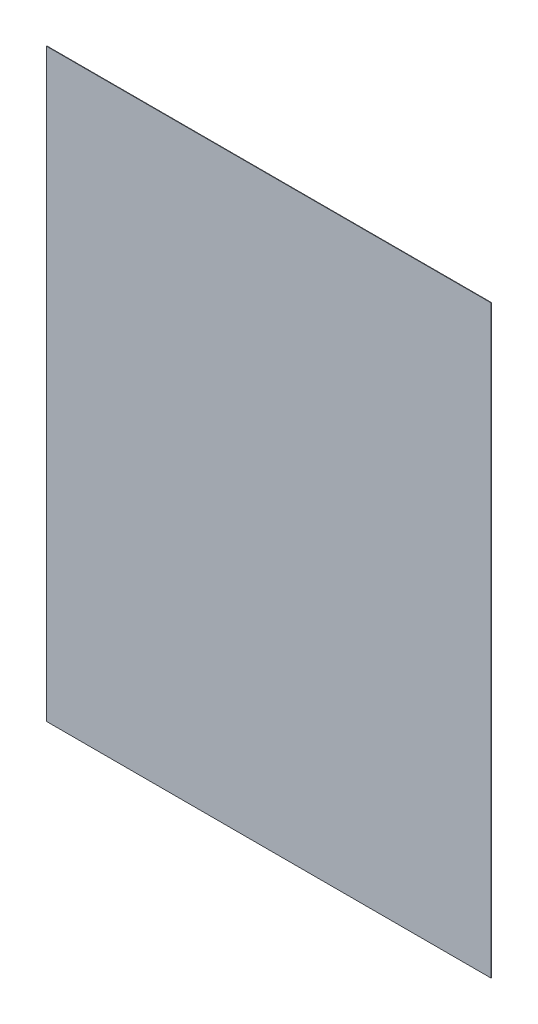
from build123d import *

# Parameters (mm, degrees)
SKETCH1_W      = 156.1
SKETCH1_H      = 205.5
POSITIVE_DEPTH = 0.1591


with BuildPart() as part:
    # Sketch1 → Positive (new body)
    with BuildSketch(Plane.XY):
        Rectangle(SKETCH1_W, SKETCH1_H)
    extrude(amount=POSITIVE_DEPTH)


solid = part.part
